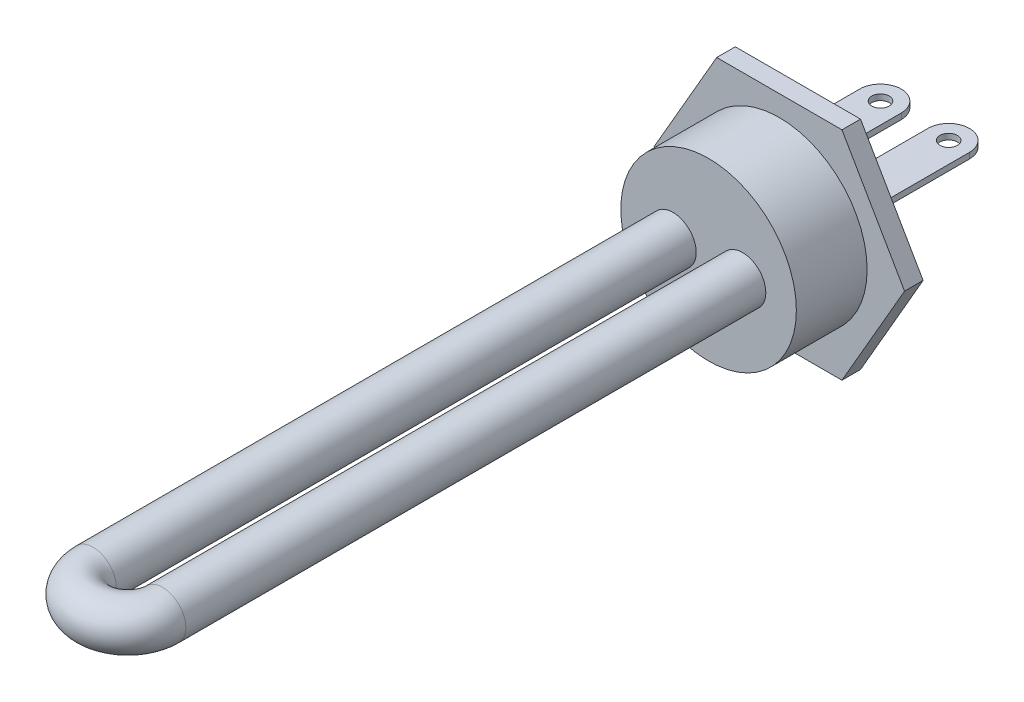
from build123d import *

# Parameters (mm, degrees)
BOSS_EXTRUDE1_DEPTH = 3.2
SKETCH2_R           = 15.135
BOSS_EXTRUDE2_DEPTH = 12.2
SKETCH3_R           = 13.5
CUT_EXTRUDE1_DEPTH  = 12.8
SWEEP1_PROFILE_R    = 4
SKETCH29_R          = 4.1
BOSS_EXTRUDE4_DEPTH = 5.7
SKETCH33_W          = 7.16
SKETCH33_H          = 1
BOSS_EXTRUDE5_DEPTH = 18
SKETCH34_R          = 1.5
CUT_EXTRUDE2_DEPTH  = 22.7


with BuildPart() as part:
    # Sketch1 → Boss-Extrude1 (new body)
    with BuildSketch(Plane.XY):
        Polygon((10.796450034, -18.7), (21.592900068, 0), (10.796450034, 18.7), (-10.796450034, 18.7), (-21.592900068, 0), (-10.796450034, -18.7), align=None)
    extrude(amount=BOSS_EXTRUDE1_DEPTH)

    # Sketch2 → Boss-Extrude2 (add)
    with BuildSketch(Plane.XY.offset(3.2)):
        Circle(SKETCH2_R)
    extrude(amount=BOSS_EXTRUDE2_DEPTH)

    # Sketch3 → Cut-Extrude1 (cut)
    with BuildSketch(Plane(origin=(0, 0, 0), x_dir=(-1, 0, 0), z_dir=(0, 0, -1))):
        Circle(SKETCH3_R)
    extrude(amount=-CUT_EXTRUDE1_DEPTH, mode=Mode.SUBTRACT)

    # Sweep1: sweep along a path in Sketch4
    with BuildLine(Plane(origin=(0, 0, 0), x_dir=(1, 0, 0), z_dir=(0, 1, 0))) as sweep1_path:
        Line((-6.135, 0), (-6.135, -115.4))
        ThreePointArc((-6.135, -115.4), (-0.135, -121.4), (5.865, -115.4))
        Line((5.865, -115.4), (5.865, 0))
    # Sweep1 profile (on start of the path) → Sweep1 (sweep)
    with BuildSketch(Plane(origin=(-6.135, 0, 0), x_dir=(1, 0, 0), z_dir=(0, 0, 1))):
        Circle(SWEEP1_PROFILE_R)
    sweep(path=sweep1_path.line)

    # Sketch29 → Boss-Extrude4 (add)
    with BuildSketch(Plane(origin=(0, 0, 0), x_dir=(-1, 0, 0), z_dir=(0, 0, -1))):
        with Locations((-5.865, 0)):
            Circle(SKETCH29_R)
        with Locations((6.135, 0)):
            Circle(SKETCH29_R)
    extrude(amount=BOSS_EXTRUDE4_DEPTH)

    # Sketch33 → Boss-Extrude5 (add)
    with BuildSketch(Plane(origin=(0, 0, -5.7), x_dir=(-1, 0, 0), z_dir=(0, 0, -1))):
        with Locations((-5.88, 2.5)):
            Rectangle(SKETCH33_W, SKETCH33_H)
        with Locations((5.88, 2.5)):
            Rectangle(SKETCH33_W, SKETCH33_H)
    extrude(amount=BOSS_EXTRUDE5_DEPTH)

    # Sketch34 → Cut-Extrude2 (cut, through all)
    with BuildSketch(Plane(origin=(0, 3, 0), x_dir=(1, 0, 0), z_dir=(0, 1, 0))):
        with BuildLine():
            ThreePointArc((-9.46, 20.12), (-8.411442277, 22.651442277), (-5.88, 23.7))
            Line((-5.88, 23.7), (-9.46, 23.7))
            Line((-9.46, 23.7), (-9.46, 20.12))
        make_face()
        with BuildLine():
            ThreePointArc((-5.88, 23.7), (-3.348557723, 22.651442277), (-2.3, 20.12))
            Line((-2.3, 20.12), (-2.3, 23.7))
            Line((-2.3, 23.7), (-5.88, 23.7))
        make_face()
        with BuildLine():
            ThreePointArc((2.3, 20.12), (3.348557723, 22.651442277), (5.88, 23.7))
            Line((5.88, 23.7), (2.3, 23.7))
            Line((2.3, 23.7), (2.3, 20.12))
        make_face()
        with BuildLine():
            ThreePointArc((5.88, 23.7), (8.411442277, 22.651442277), (9.46, 20.12))
            Line((9.46, 20.12), (9.46, 23.7))
            Line((9.46, 23.7), (5.88, 23.7))
        make_face()
        with Locations((-5.88, 20.12)):
            Circle(SKETCH34_R)
        with Locations((5.88, 20.12)):
            Circle(SKETCH34_R)
    extrude(amount=-CUT_EXTRUDE2_DEPTH, mode=Mode.SUBTRACT)


solid = part.part
